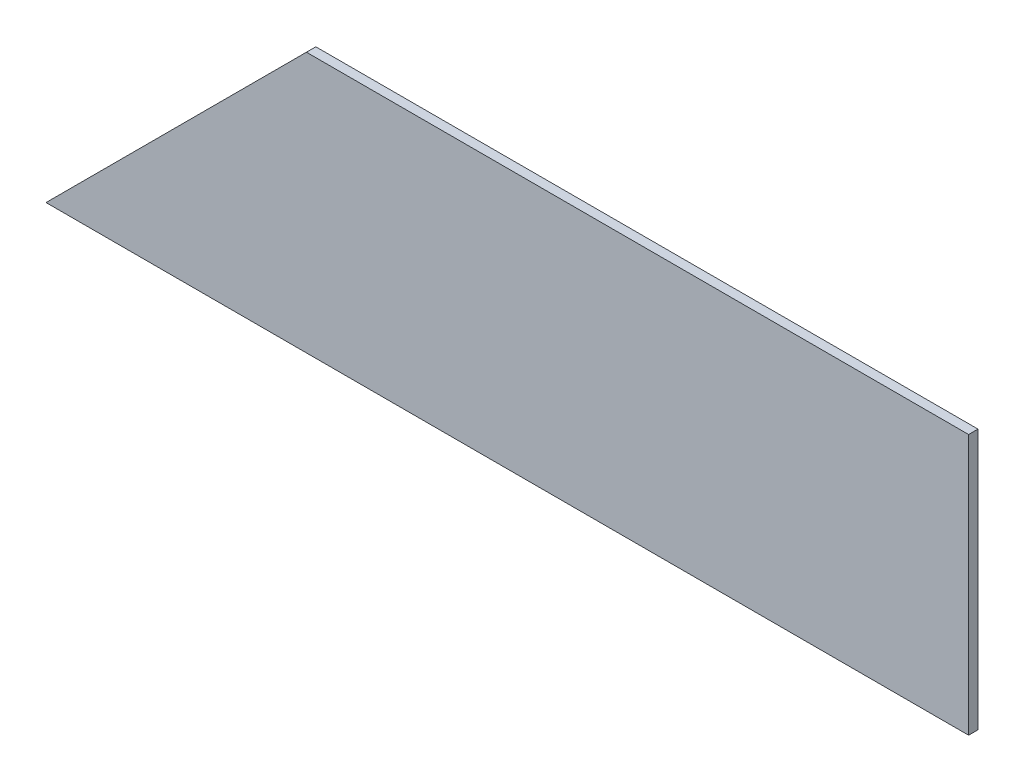
from build123d import *

# Parameters (mm, degrees)
BOSS_EXTRUDE1_DEPTH = 3


with BuildPart() as part:
    # Sketch1 → Boss-Extrude1 (new body)
    with BuildSketch(Plane.XY):
        Polygon((416.466548048, 276.80916598), (711.17673453, 276.80916598), (711.17673453, 360), (499.657382069, 360), align=None)
    extrude(amount=-BOSS_EXTRUDE1_DEPTH)


solid = part.part
